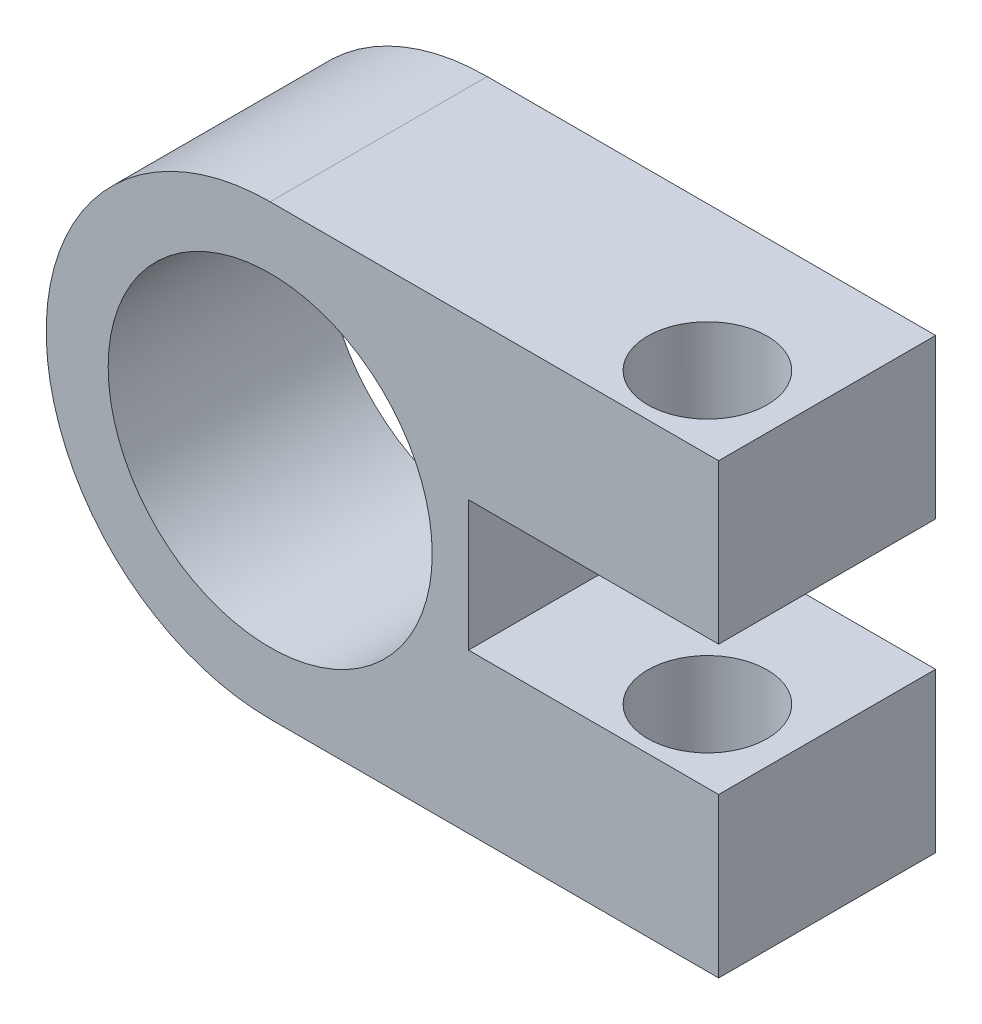
from build123d import *

# Parameters (mm, degrees)
SKETCH1_R           = 11.2
BOSS_EXTRUDE1_DEPTH = 15
SKETCH2_R           = 4.125
CUT_EXTRUDE1_DEPTH  = 38
CUT_EXTRUDE2_DEPTH  = 38


with BuildPart() as part:
    # Sketch1 → Boss-Extrude1 (new body)
    with BuildSketch(Plane.XY):
        with BuildLine():
            Line((0, 15.483636231), (31, 15.483636231))
            Line((31, 15.483636231), (31, -15.483636231))
            Line((31, -15.483636231), (0, -15.483636231))
            ThreePointArc((0, -15.483636231), (-15.483636231, 0), (0, 15.483636231))
        make_face()
        Circle(SKETCH1_R, mode=Mode.SUBTRACT)
    extrude(amount=BOSS_EXTRUDE1_DEPTH)

    # Sketch2 → Cut-Extrude1 (cut)
    with BuildSketch(Plane.XZ.offset(15.483636231)):
        with Locations((25.207969837, 9.982935424)):
            Circle(SKETCH2_R)
    extrude(amount=-CUT_EXTRUDE1_DEPTH, mode=Mode.SUBTRACT)

    # Sketch7 → Cut-Extrude2 (cut)
    with BuildSketch(Plane.XY.offset(15)):
        Polygon((25.458117285, 4.5), (13.708117285, 4.5), (13.708117285, -4.5), (31, -4.5), (31, 4.5), align=None)
    extrude(amount=-CUT_EXTRUDE2_DEPTH, mode=Mode.SUBTRACT)


solid = part.part
